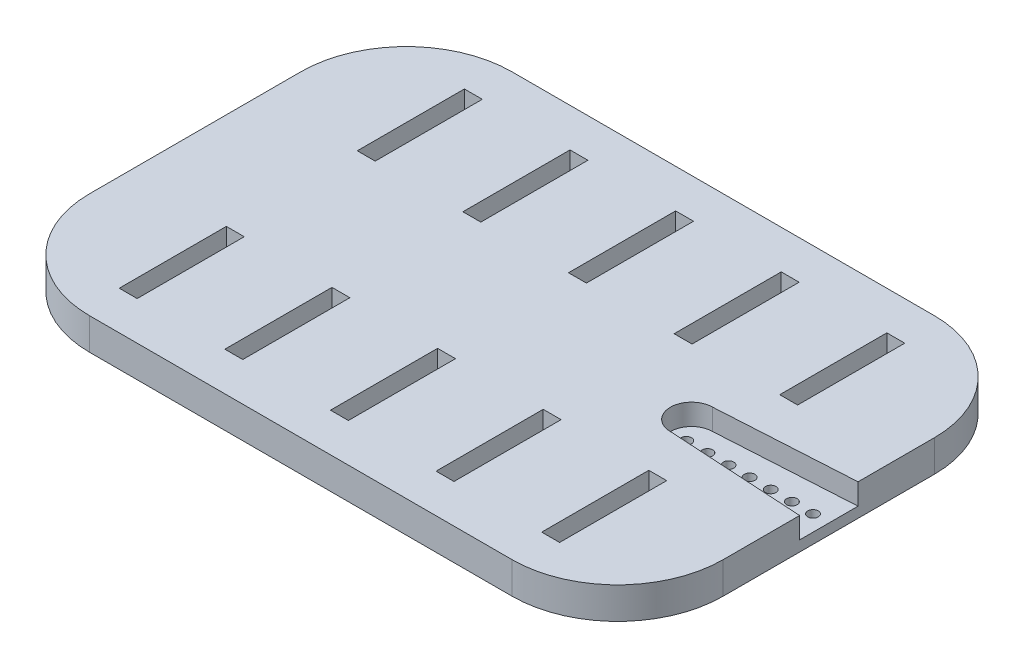
from build123d import *

# Parameters (mm, degrees)
SKETCH_1_W          = 60
SKETCH_1_H          = 40
EXTRUDE_1_DEPTH     = 3
FILLET_1_R          = 10
SKETCH_2_W          = 1.695959674
SKETCH_2_H          = 10.142260461
CUT_EXTRUDE_1_DEPTH = 4
CUT_EXTRUDE_2_DEPTH = 2
SKETCH_4_R          = 0.5
CUT_EXTRUDE_3_DEPTH = 2


with BuildPart() as part:
    # 草图1 → 凸台-拉伸1 (new body)
    with BuildSketch(Plane(origin=(0, 0, 0), x_dir=(1, 0, 0), z_dir=(0, 1, 0))):
        Rectangle(SKETCH_1_W, SKETCH_1_H)
    extrude(amount=EXTRUDE_1_DEPTH)

    # 圆角1
    fillet_1_edges = [part.edges().sort_by_distance(p)[0] for p in [
        (30, 1.5, 20),
        (-30, 1.5, 20),
        (-30, 1.5, -20),
        (30, 1.5, -20),
    ]]
    fillet(fillet_1_edges, radius=FILLET_1_R)

    # 草图2 → 切除-拉伸1 (cut, through all)
    with BuildSketch(Plane(origin=(0, 3, 0), x_dir=(1, 0, 0), z_dir=(0, 1, 0))):
        with Locations((-20, 11.269178291)):
            Rectangle(SKETCH_2_W, SKETCH_2_H)
        with Locations((-10, 11.269178291)):
            Rectangle(SKETCH_2_W, SKETCH_2_H)
        with Locations((0, 11.269178291)):
            Rectangle(SKETCH_2_W, SKETCH_2_H)
        with Locations((10, 11.269178291)):
            Rectangle(SKETCH_2_W, SKETCH_2_H)
        with Locations((20, 11.269178291)):
            Rectangle(SKETCH_2_W, SKETCH_2_H)
        with Locations((20, -11.269178291)):
            Rectangle(SKETCH_2_W, SKETCH_2_H)
        with Locations((10, -11.269178291)):
            Rectangle(SKETCH_2_W, SKETCH_2_H)
        with Locations((0, -11.269178291)):
            Rectangle(SKETCH_2_W, SKETCH_2_H)
        with Locations((-10, -11.269178291)):
            Rectangle(SKETCH_2_W, SKETCH_2_H)
        with Locations((-20, -11.269178291)):
            Rectangle(SKETCH_2_W, SKETCH_2_H)
    extrude(amount=-CUT_EXTRUDE_1_DEPTH, mode=Mode.SUBTRACT)

    # 草图3 → 切除-拉伸2 (cut)
    with BuildSketch(Plane(origin=(0, 3, 0), x_dir=(1, 0, 0), z_dir=(0, 1, 0))):
        with BuildLine():
            Line((34, 3), (34, -3))
            Line((34, -3), (17, -2))
            ThreePointArc((17, -2), (15, 0), (17, 2))
            Line((17, 2), (34, 3))
        make_face()
    extrude(amount=-CUT_EXTRUDE_2_DEPTH, mode=Mode.SUBTRACT)

    # 草图4 → 切除-拉伸3 (cut, through all)
    with BuildSketch(Plane(origin=(0, 1, 0), x_dir=(1, 0, 0), z_dir=(0, 1, 0))):
        with Locations((16.5, 0)):
            Circle(SKETCH_4_R)
        with Locations((18.5, 0)):
            Circle(SKETCH_4_R)
        with Locations((20.5, 0)):
            Circle(SKETCH_4_R)
        with Locations((22.5, 0)):
            Circle(SKETCH_4_R)
        with Locations((24.5, 0)):
            Circle(SKETCH_4_R)
        with Locations((26.5, 0)):
            Circle(SKETCH_4_R)
        with Locations((28.5, 0)):
            Circle(SKETCH_4_R)
    extrude(amount=-CUT_EXTRUDE_3_DEPTH, mode=Mode.SUBTRACT)


solid = part.part
